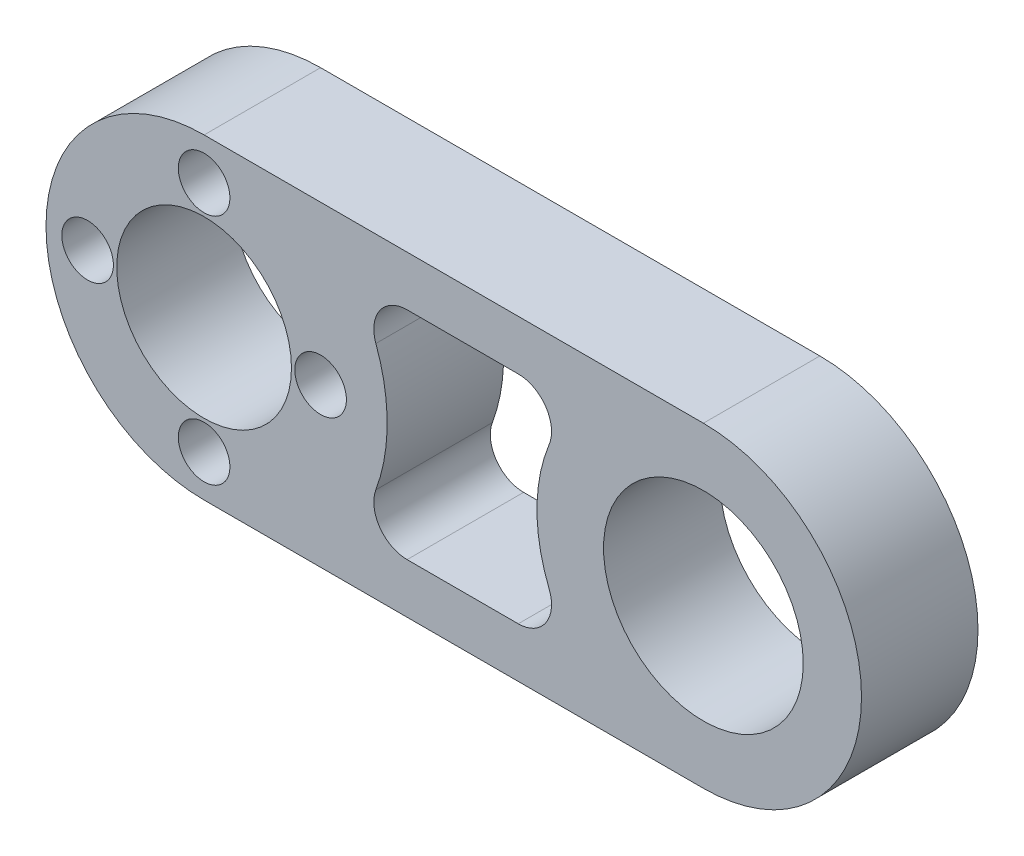
from build123d import *

# Parameters (mm, degrees)
SKETCH_1_R      = 5.25
SKETCH_1_R_2    = 6
SKETCH_1_R_3    = 1.55
EXTRUDE_1_DEPTH = 7
FILLET_1_R      = 2


with BuildPart() as part:
    # 草图1 → 凸台-拉伸1 (new body)
    with BuildSketch(Plane.XY):
        with BuildLine():
            Line((0, 9.5), (30, 9.5))
            ThreePointArc((30, 9.5), (39.5, 0), (30, -9.5))
            Line((30, -9.5), (0, -9.5))
            ThreePointArc((0, -9.5), (-9.5, 0), (0, 9.5))
        make_face()
        Circle(SKETCH_1_R, mode=Mode.SUBTRACT)
        with Locations((30, 0)):
            Circle(SKETCH_1_R_2, mode=Mode.SUBTRACT)
        with Locations((0, -7)):
            Circle(SKETCH_1_R_3, mode=Mode.SUBTRACT)
        with Locations((-7, 0)):
            Circle(SKETCH_1_R_3, mode=Mode.SUBTRACT)
        with Locations((0, 7)):
            Circle(SKETCH_1_R_3, mode=Mode.SUBTRACT)
        with Locations((7, 0)):
            Circle(SKETCH_1_R_3, mode=Mode.SUBTRACT)
        with BuildLine():
            Line((22.400657923, -6.5), (8.874119675, -6.5))
            ThreePointArc((8.874119675, -6.5), (11, 0), (8.874119675, 6.5))
            Line((8.874119675, 6.5), (22.400657923, 6.5))
            ThreePointArc((22.400657923, 6.5), (20, 0), (22.400657923, -6.5))
        make_face(mode=Mode.SUBTRACT)
    extrude(amount=EXTRUDE_1_DEPTH)

    # 圆角1
    fillet_1_edges = [part.edges().sort_by_distance(p)[0] for p in [
        (22.400657923, -6.5, 3.5),
        (22.400657923, 6.5, 3.5),
        (8.874119675, 6.5, 3.5),
        (8.874119675, -6.5, 3.5),
    ]]
    fillet(fillet_1_edges, radius=FILLET_1_R)


solid = part.part
